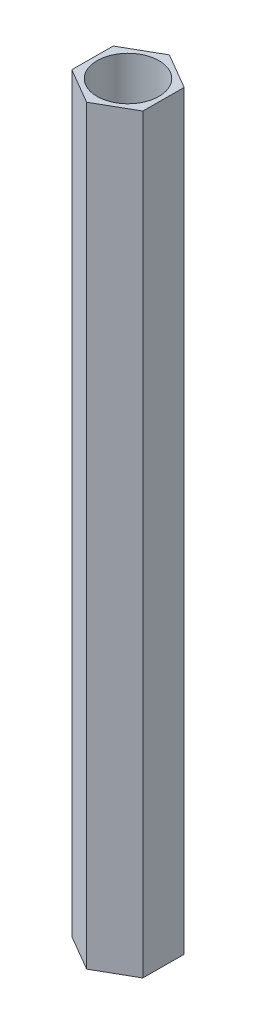
from build123d import *

# Parameters (mm, degrees)
SKETCH1_R           = 1.65
BOSS_EXTRUDE1_DEPTH = 40


with BuildPart() as part:
    # Sketch1 → Boss-Extrude1 (new body)
    with BuildSketch(Plane(origin=(0, 0, 0), x_dir=(1, 0, 0), z_dir=(0, 1, 0))):
        Polygon((1.894478714, -1.106473559), (1.905473568, 1.087429913), (0.010994854, 2.193903472), (-1.894478714, 1.106473559), (-1.905473568, -1.087429913), (-0.010994854, -2.193903472), align=None)
        Circle(SKETCH1_R, mode=Mode.SUBTRACT)
    extrude(amount=BOSS_EXTRUDE1_DEPTH)


solid = part.part
